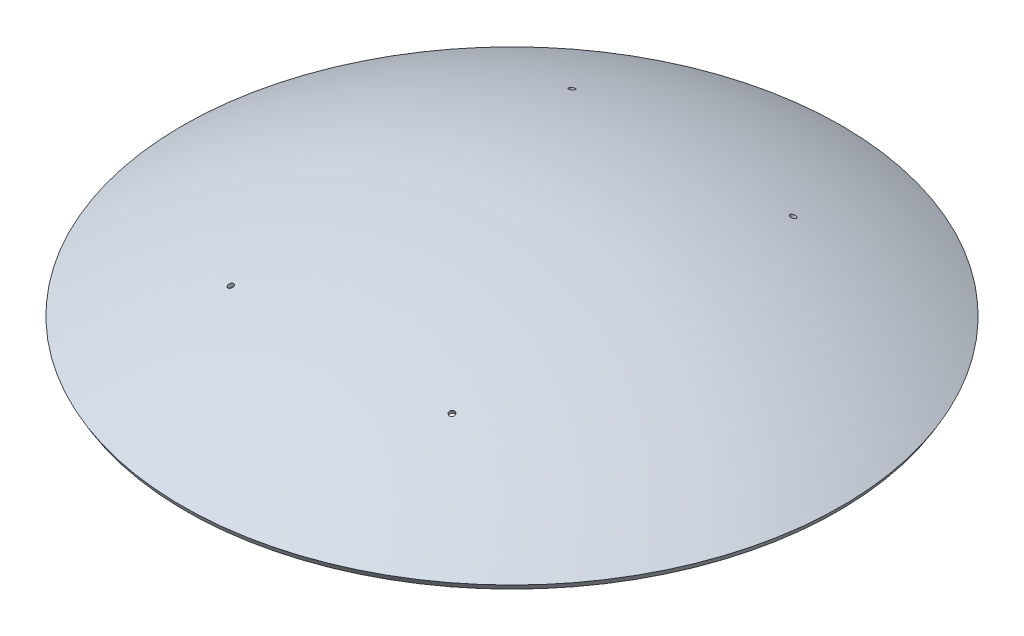
from build123d import *


with BuildPart() as part:
    # Sketch1 → Revolve1 (revolve)
    with BuildSketch(Plane.XY):
        with BuildLine():
            ThreePointArc((-118125, 204598.501644073), (-61145.999405471, 228199.976460792), (0, 236250))
            Line((0, 236250), (0, 237500))
            ThreePointArc((0, 237500), (-61469.523211849, 229407.383743654), (-118750, 205681.033398804))
            Line((-118750, 205681.033398804), (-118125, 204598.501644073))
        make_face()
        with BuildLine():
            ThreePointArc((-117500, 203515.969889343), (-60822.475599093, 226992.569177931), (0, 235000))
            Line((0, 235000), (0, 236250))
            ThreePointArc((0, 236250), (-61145.999405471, 228199.976460792), (-118125, 204598.501644073))
            Line((-118125, 204598.501644073), (-117500, 203515.969889343))
        make_face()
    revolve(axis=Axis((0, 0, 0), (0, 1, 0)))

    # Sketch3 → Cut-Revolve1 (revolve, cut)
    with BuildSketch(Plane(origin=(0, 0, 0), x_dir=(0, 0, -1), z_dir=(0.984807753012208, -0.17364817766693072, 0)), mode=Mode.PRIVATE) as cut_revolve1_sk:
        with BuildLine():
            Line((-61469.523211849, 229407.383743654), (-61145.999405471, 228199.976460792))
            ThreePointArc((-61145.999405471, 228199.976460792), (-60662.898468624, 228328.875198441), (-60179.525811555, 228456.751209275))
            Line((-60179.525811553, 228456.751209275), (-60503.052500945, 229664.169251688))
            ThreePointArc((-60503.052500946, 229664.169251688), (-60986.423007114, 229536.285168157), (-61469.523211849, 229407.383743654))
        make_face()
        with BuildLine():
            Line((-61145.999405471, 228199.976460792), (-60822.475599093, 226992.569177931))
            ThreePointArc((-60822.475599093, 226992.569177931), (-60339.373922288, 227121.465200157), (-59855.999091498, 227249.333052396))
            Line((-59855.999091491, 227249.333052397), (-60179.525811553, 228456.751209275))
            ThreePointArc((-60179.525811555, 228456.751209275), (-60662.898468624, 228328.875198441), (-61145.999405471, 228199.976460792))
        make_face()
        with BuildLine():
            Line((-60179.525811553, 228456.751209275), (-59855.999091491, 227249.333052397))
            ThreePointArc((-59855.999091498, 227249.333052396), (-58888.403659222, 227501.991012098), (-57919.741808911, 227750.529107594))
            Line((-57919.741808911, 227750.529107594), (-58243.291841278, 228958.034267181))
            ThreePointArc((-58243.291841278, 228958.034267181), (-59211.939306065, 228709.441745668), (-60179.525811555, 228456.751209275))
        make_face()
    cut_revolve1 = revolve(cut_revolve1_sk.sketch.rotate(Axis((35107.466143794, 199104.334474144, 54172.852994611), (0.16773125949652093, 0.9512512425641976, 0.25881904510252157)), 2.612981902), axis=Axis((35107.466143794, 199104.334474144, 54172.852994611), (0.16773125949652093, 0.9512512425641976, 0.25881904510252157)), mode=Mode.SUBTRACT)

    # Mirror1: Cut-Revolve1 across plane
    add(cut_revolve1.mirror(Plane(origin=(0, 0, 0), x_dir=(0, 0, 1), z_dir=(1, 0, 0))), mode=Mode.SUBTRACT)

    # Mirror2: Cut-Revolve1 across plane
    add(cut_revolve1.mirror(Plane.XY), mode=Mode.SUBTRACT)

    # Mirror2 copy 1 sketch → Mirror2 copy 1 (revolve, cut)
    with BuildSketch(Plane(origin=(0, 0, 0), x_dir=(0, 0, 1), z_dir=(-0.984807753012208, -0.17364817766693072, 0))):
        with BuildLine():
            Line((-61469.523211849, 229407.383743654), (-61145.999405471, 228199.976460792))
            ThreePointArc((-61145.999405471, 228199.976460792), (-60662.898468624, 228328.875198441), (-60179.525811555, 228456.751209275))
            Line((-60179.525811553, 228456.751209275), (-60503.052500945, 229664.169251688))
            ThreePointArc((-60503.052500946, 229664.169251688), (-60986.423007114, 229536.285168157), (-61469.523211849, 229407.383743654))
        make_face()
        with BuildLine():
            Line((-61145.999405471, 228199.976460792), (-60822.475599093, 226992.569177931))
            ThreePointArc((-60822.475599093, 226992.569177931), (-60339.373922288, 227121.465200157), (-59855.999091498, 227249.333052396))
            Line((-59855.999091491, 227249.333052397), (-60179.525811553, 228456.751209275))
            ThreePointArc((-60179.525811555, 228456.751209275), (-60662.898468624, 228328.875198441), (-61145.999405471, 228199.976460792))
        make_face()
        with BuildLine():
            Line((-60179.525811553, 228456.751209275), (-59855.999091491, 227249.333052397))
            ThreePointArc((-59855.999091498, 227249.333052396), (-58888.403659222, 227501.991012098), (-57919.741808911, 227750.529107594))
            Line((-57919.741808911, 227750.529107594), (-58243.291841278, 228958.034267181))
            ThreePointArc((-58243.291841278, 228958.034267181), (-59211.939306065, 228709.441745668), (-60179.525811555, 228456.751209275))
        make_face()
    revolve(axis=Axis((-35107.466143794, 199104.334474144, -54172.852994611), (-0.16773125949652093, 0.9512512425641976, -0.25881904510252157)), mode=Mode.SUBTRACT)


solid = part.part
